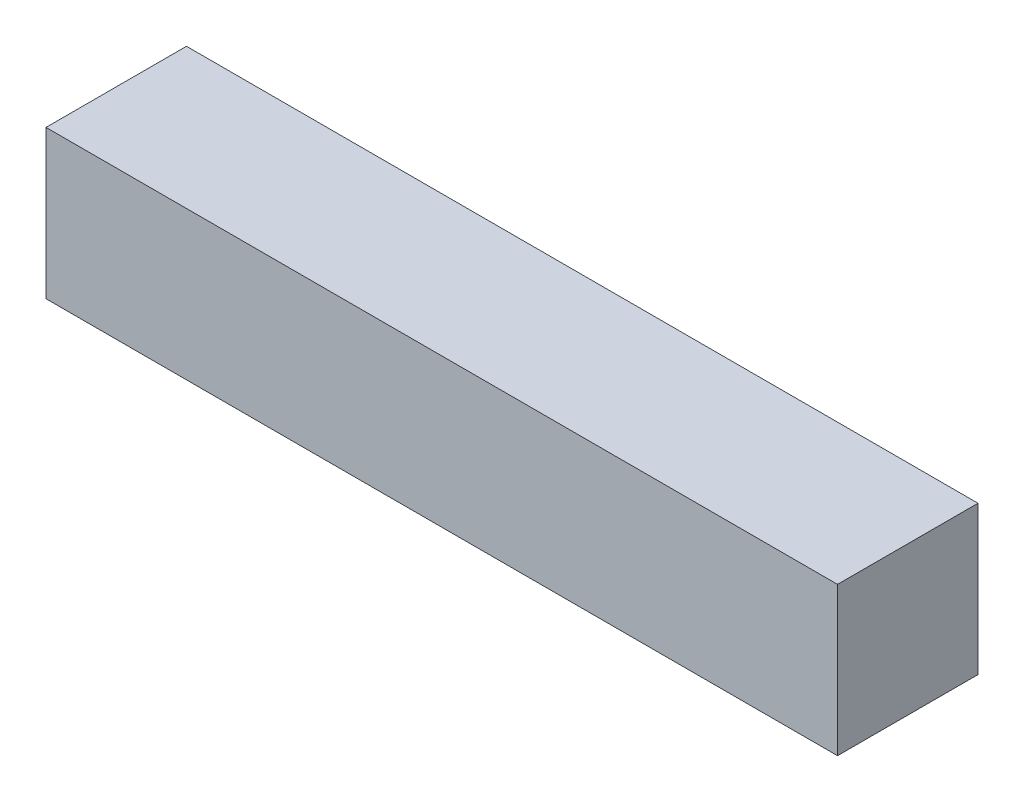
from build123d import *

# Parameters (mm, degrees)
SKETCH2_W           = 203.2
SKETCH2_H           = 36.068
BOSS_EXTRUDE1_DEPTH = 38.1


with BuildPart() as part:
    # Sketch2 → Boss-Extrude1 (new body)
    with BuildSketch(Plane(origin=(0, 0, 0), x_dir=(1, 0, 0), z_dir=(0, 1, 0))):
        Rectangle(SKETCH2_W, SKETCH2_H)
    extrude(amount=BOSS_EXTRUDE1_DEPTH)


solid = part.part
